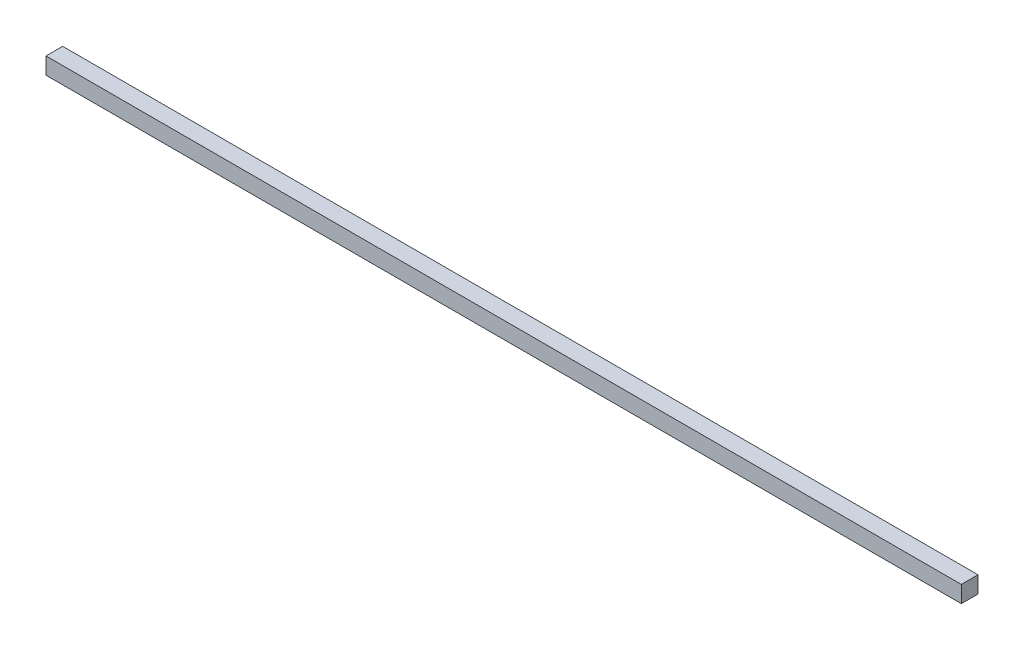
from build123d import *

# Parameters (mm, degrees)
SKETCH1_W           = 548.53
SKETCH1_H           = 10
BOSS_EXTRUDE1_DEPTH = 10


with BuildPart() as part:
    # Sketch1 → Boss-Extrude1 (new body)
    with BuildSketch(Plane(origin=(0, 0, 0), x_dir=(1, 0, 0), z_dir=(0, 1, 0))):
        Rectangle(SKETCH1_W, SKETCH1_H)
    extrude(amount=BOSS_EXTRUDE1_DEPTH)


solid = part.part
